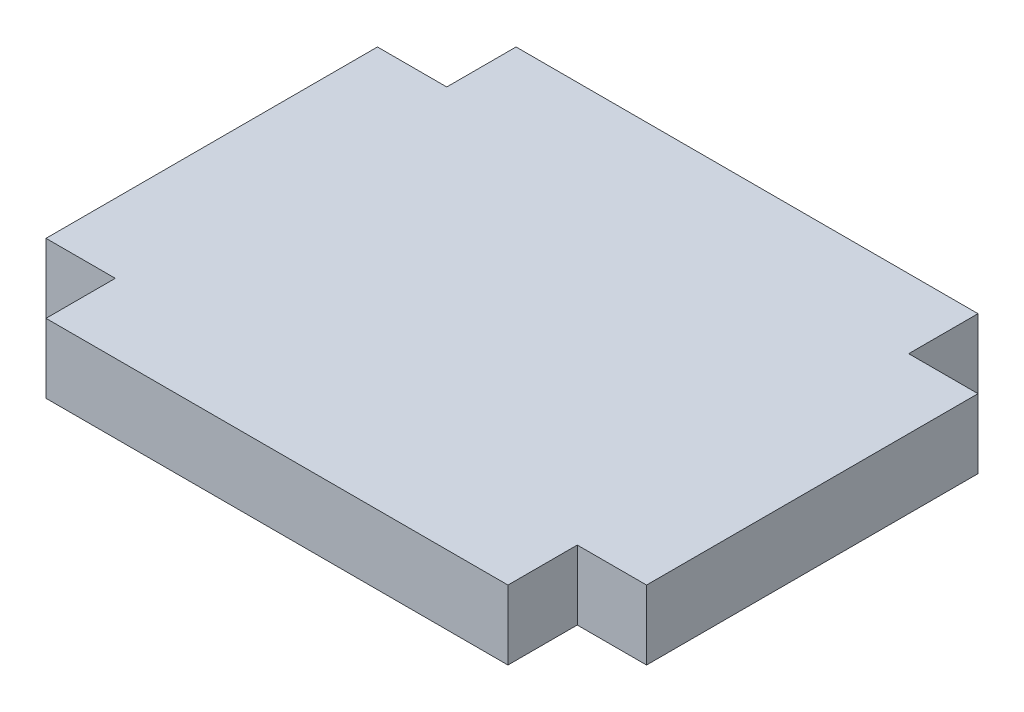
from build123d import *

# Parameters (mm, degrees)
BOSS_EXTRUDE1_DEPTH = 1.5


with BuildPart() as part:
    # Sketch1 → Boss-Extrude1 (new body, symmetric)
    with BuildSketch(Plane(origin=(0, 0, 0), x_dir=(1, 0, 0), z_dir=(0, 1, 0))):
        Polygon((-10, 10.175), (10, 10.175), (10, 7.175), (13, 7.175), (13, -7.175), (10, -7.175), (10, -10.175), (-10, -10.175), (-10, -7.175), (-13, -7.175), (-13, 7.175), (-10, 7.175), align=None)
    extrude(amount=BOSS_EXTRUDE1_DEPTH, both=True)


solid = part.part
